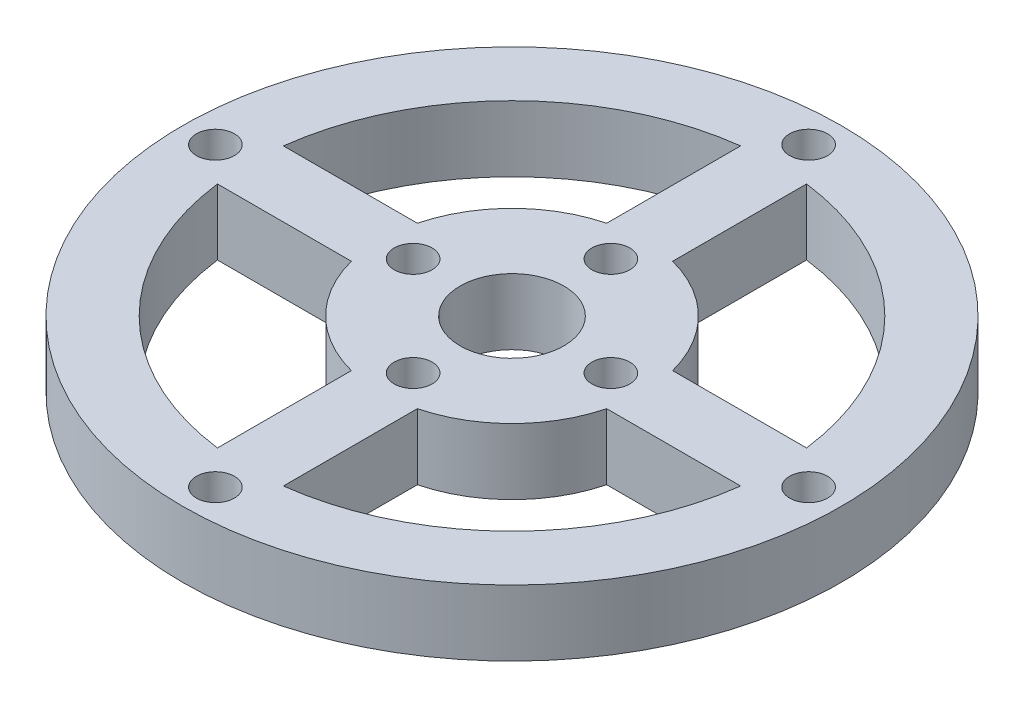
from build123d import *

# Parameters (mm, degrees)
SKETCH1_R                      = 31.75
SKETCH1_R_2                    = 25.4
SKETCH1_R_3                    = 12.7
SKETCH1_R_4                    = 5
BOSS_EXTRUDE1_DEPTH            = 6.35
F_6_CLEARANCE_HOLE1_AT_2_COUNT = 2
F_6_CLEARANCE_HOLE1_AT_2_PITCH = 19.05
CIRPATTERN1_COUNT              = 4


with BuildPart() as part:
    # Sketch1 → Boss-Extrude1 (new body)
    with BuildSketch(Plane(origin=(0, 0, 0), x_dir=(1, 0, 0), z_dir=(0, 1, 0))):
        Circle(SKETCH1_R)
        Circle(SKETCH1_R_2, mode=Mode.SUBTRACT)
        Circle(SKETCH1_R_3)
        Circle(SKETCH1_R_4, mode=Mode.SUBTRACT)
        with BuildLine():
            ThreePointArc((-12.296722124, -3.175), (-12.7, 0), (-12.296722124, 3.175))
            Line((-12.296722124, 3.175), (-25.200781238, 3.175))
            ThreePointArc((-25.200781238, 3.175), (-25.4, 0), (-25.200781238, -3.175))
            Line((-25.200781238, -3.175), (-12.296722124, -3.175))
        make_face()
        with BuildLine():
            Line((-3.175, 25.200781238), (-3.175, 12.296722124))
            ThreePointArc((-3.175, 12.296722124), (0, 12.7), (3.175, 12.296722124))
            Line((3.175, 12.296722124), (3.175, 25.200781238))
            ThreePointArc((3.175, 25.200781238), (0, 25.4), (-3.175, 25.200781238))
        make_face()
        with BuildLine():
            Line((25.200781238, 3.175), (12.296722124, 3.175))
            ThreePointArc((12.296722124, 3.175), (12.598777143, 1.600254515), (12.7, 0))
            ThreePointArc((12.7, 0), (12.598777143, -1.600254515), (12.296722124, -3.175))
            Line((12.296722124, -3.175), (25.200781238, -3.175))
            ThreePointArc((25.200781238, -3.175), (25.350146385, -1.590621979), (25.4, 0))
            ThreePointArc((25.4, 0), (25.350146385, 1.590621979), (25.200781238, 3.175))
        make_face()
        with BuildLine():
            ThreePointArc((3.175, -12.296722124), (0, -12.7), (-3.175, -12.296722124))
            Line((-3.175, -12.296722124), (-3.175, -25.200781238))
            ThreePointArc((-3.175, -25.200781238), (0, -25.4), (3.175, -25.200781238))
            Line((3.175, -25.200781238), (3.175, -12.296722124))
        make_face()
    extrude(amount=BOSS_EXTRUDE1_DEPTH)

    # Sketch2 → #6 Clearance Hole1 (revolve, cut)
    with BuildSketch(Plane(origin=(0, 6.35, 28.575), x_dir=(0, 0, 1), z_dir=(1, 0, 0))):
        Polygon((0, 0), (0, 13.7988539), (1.8288, 12.7), (1.8288, 0), align=None)
    f_6_clearance_hole1 = revolve(axis=Axis((0, 12.7, 28.575), (0, -1, 0)), mode=Mode.SUBTRACT)

    # #6 Clearance Hole1 at 2: #6 Clearance Hole1 ×2
    with Locations(*[(0, 0, -i * F_6_CLEARANCE_HOLE1_AT_2_PITCH) for i in range(1, F_6_CLEARANCE_HOLE1_AT_2_COUNT)]):
        add(f_6_clearance_hole1, mode=Mode.SUBTRACT)

    # CirPattern1: #6 Clearance Hole1 ×4 about axis
    cirpattern1_axis = Axis((0, 0, 0), (0, 1, 0))
    for i in range(1, CIRPATTERN1_COUNT):
        add(f_6_clearance_hole1.rotate(cirpattern1_axis, i * 360 / CIRPATTERN1_COUNT), mode=Mode.SUBTRACT)

    # CirPattern1 copy 1 sketch → CirPattern1 copy 1 (revolve, cut)
    with BuildSketch(Plane(origin=(9.525, 6.35, 0), x_dir=(1, 0, 0), z_dir=(0, 0, -1))):
        Polygon((0, 0), (0, 13.7988539), (1.8288, 12.7), (1.8288, 0), align=None)
    revolve(axis=Axis((9.525, 12.7, 0), (0, -1, 0)), mode=Mode.SUBTRACT)

    # CirPattern1 copy 2 sketch → CirPattern1 copy 2 (revolve, cut)
    with BuildSketch(Plane(origin=(0, 6.35, -9.525), x_dir=(0, 0, -1), z_dir=(-1, 0, 0))):
        Polygon((0, 0), (0, 13.7988539), (1.8288, 12.7), (1.8288, 0), align=None)
    revolve(axis=Axis((0, 12.7, -9.525), (0, -1, 0)), mode=Mode.SUBTRACT)

    # CirPattern1 copy 3 sketch → CirPattern1 copy 3 (revolve, cut)
    with BuildSketch(Plane(origin=(-9.525, 6.35, 0), x_dir=(-1, 0, 0), z_dir=(0, 0, 1))):
        Polygon((0, 0), (0, 13.7988539), (1.8288, 12.7), (1.8288, 0), align=None)
    revolve(axis=Axis((-9.525, 12.7, 0), (0, -1, 0)), mode=Mode.SUBTRACT)


solid = part.part
